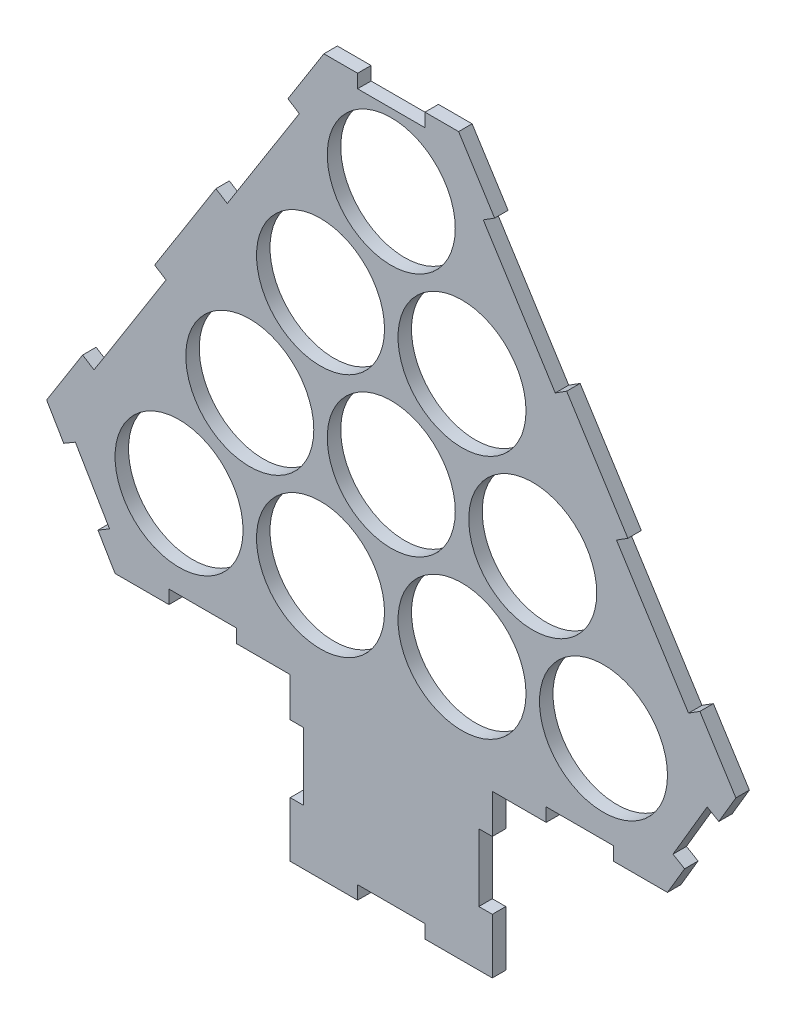
from build123d import *

# Parameters (mm, degrees)
ESQUISSE1_R             = 47.5
BOSS_EXTRU_1_DEPTH      = 10
ESQUISSE9_W             = 150
ESQUISSE9_H             = 120
BOSS_EXTRU_2_DEPTH      = 10
ESQUISSE10_W            = 10
ESQUISSE10_H            = 50
ESQUISSE10_W_2          = 50
ESQUISSE10_H_2          = 10
ENL_V_MAT_EXTRU_1_DEPTH = 10


with BuildPart() as part:
    # Esquisse1 → Boss.-Extru.1 (new body)
    with BuildSketch(Plane.XY):
        Polygon((-255.775862069, 10.959681362), (-205, -75.190256718), (205, -75.190256718), (255.775862069, 10.959681362), (50, 336.353741833), (-50, 336.353741833), align=None)
        with Locations((-157.5, 0)):
            Circle(ESQUISSE1_R, mode=Mode.SUBTRACT)
        with Locations((-52.5, 0)):
            Circle(ESQUISSE1_R, mode=Mode.SUBTRACT)
        with Locations((52.5, 0)):
            Circle(ESQUISSE1_R, mode=Mode.SUBTRACT)
        with Locations((157.5, 0)):
            Circle(ESQUISSE1_R, mode=Mode.SUBTRACT)
        with Locations((-105, 90.932667397)):
            Circle(ESQUISSE1_R, mode=Mode.SUBTRACT)
        with Locations((0, 90.932667397)):
            Circle(ESQUISSE1_R, mode=Mode.SUBTRACT)
        with Locations((105, 90.932667397)):
            Circle(ESQUISSE1_R, mode=Mode.SUBTRACT)
        with Locations((-52.5, 181.865334795)):
            Circle(ESQUISSE1_R, mode=Mode.SUBTRACT)
        with Locations((52.5, 181.865334795)):
            Circle(ESQUISSE1_R, mode=Mode.SUBTRACT)
        with Locations((0, 272.798002192)):
            Circle(ESQUISSE1_R, mode=Mode.SUBTRACT)
    extrude(amount=BOSS_EXTRU_1_DEPTH)

    # Esquisse9 → Boss.-Extru.2 (add)
    with BuildSketch(Plane.XY.offset(10)):
        with Locations((0, -135.190256718)):
            Rectangle(ESQUISSE9_W, ESQUISSE9_H)
    extrude(amount=-BOSS_EXTRU_2_DEPTH)

    # Esquisse10 → Enlèv. mat.-Extru.1 (cut)
    with BuildSketch(Plane.XY.offset(10)):
        with Locations((-70, -129.244737692)):
            Rectangle(ESQUISSE10_W, ESQUISSE10_H)
        with Locations((0, -190.190256718)):
            Rectangle(ESQUISSE10_W_2, ESQUISSE10_H_2)
        with Locations((-140, -70.190256718)):
            Rectangle(ESQUISSE10_W_2, ESQUISSE10_H_2)
        Polygon((-217.693965517, -53.652772198), (-209.078971709, -48.575185991), (-234.466902744, -5.500216951), (-243.081896552, -10.577803158), align=None)
        Polygon((-229.051724138, 53.218650255), (-220.599930359, 47.873822668), (-167.151654497, 132.391760453), (-175.603448276, 137.736588039), align=None)
        Polygon((-130.172413793, 209.576835156), (-121.720620015, 204.23200757), (-68.272344153, 288.749945355), (-76.724137931, 294.094772941), align=None)
        with Locations((0, 331.353741833)):
            Rectangle(ESQUISSE10_W_2, ESQUISSE10_H_2)
        Polygon((68.272344153, 288.749945355), (76.724137931, 294.094772941), (130.172413793, 209.576835156), (121.720620015, 204.23200757), align=None)
        Polygon((167.151654497, 132.391760453), (175.603448276, 137.736588039), (229.051724138, 53.218650255), (220.599930359, 47.873822668), align=None)
        Polygon((234.466902744, -5.500216951), (243.081896552, -10.577803158), (217.693965517, -53.652772198), (209.078971709, -48.575185991), align=None)
        with Locations((140, -70.190256718)):
            Rectangle(ESQUISSE10_W_2, ESQUISSE10_H_2)
        with Locations((70, -129.244737692)):
            Rectangle(ESQUISSE10_W, ESQUISSE10_H)
    extrude(amount=-ENL_V_MAT_EXTRU_1_DEPTH, mode=Mode.SUBTRACT)


solid = part.part
